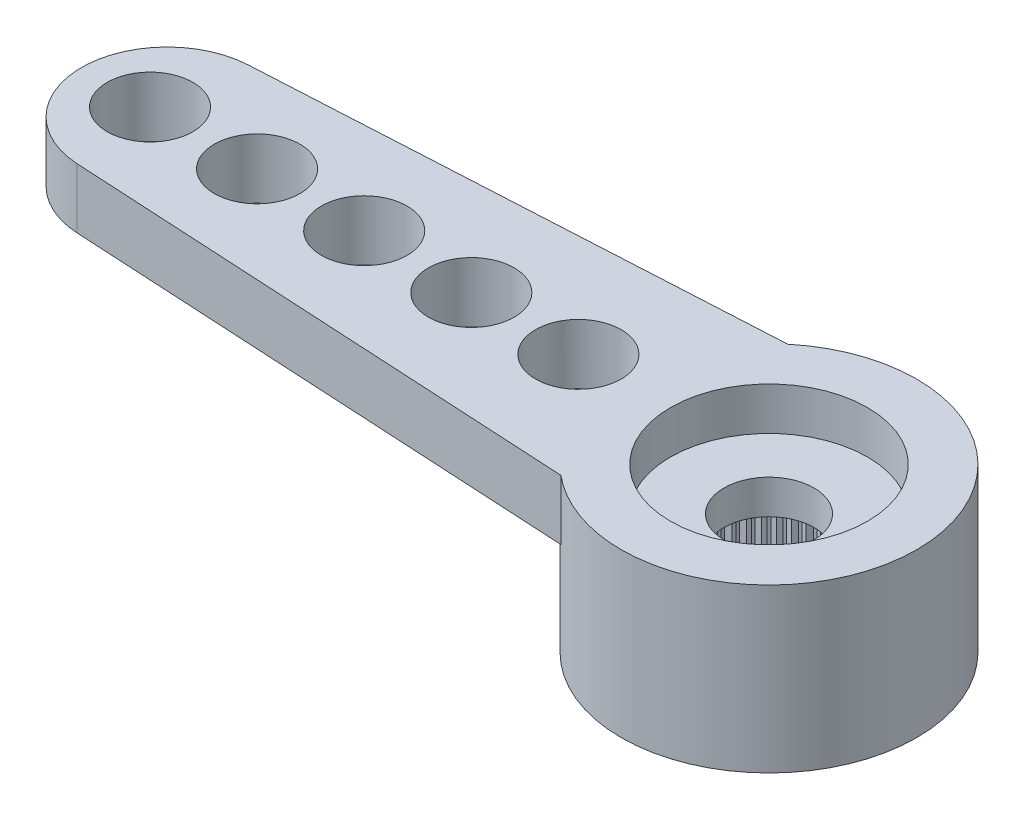
from build123d import *

# Parameters (mm, degrees)
RESSALTO_EXTRUS_O1_DEPTH = 1.4
ESBO_O2_R                = 3.45
RESSALTO_EXTRUS_O2_DEPTH = 2.4
FURO4_D                  = 2
PADR_O_LINEAR1_COUNT     = 5
PADR_O_LINEAR1_PITCH     = 2.5
FURO1_D                  = 4.95
FURO1_DEPTH              = 2
FURO2_D                  = 4.6
FURO2_DEPTH              = 1
FURO3_D                  = 2.1
RESSALTO_EXTRUS_O3_DEPTH = 2
PADR_OCIRCULAR1_COUNT    = 60


with BuildPart() as part:
    # Esboço1 → Ressalto-extrusão1 (new body)
    with BuildSketch(Plane(origin=(0, 0, 0), x_dir=(1, 0, 0), z_dir=(0, 1, 0))):
        with BuildLine():
            Line((-14.159121967, 1.99702088), (-2.209072203, 2.65))
            ThreePointArc((-2.209072203, 2.65), (3.45, 0), (-2.209072203, -2.65))
            Line((-2.209072203, -2.65), (-14.159121967, -1.99702088))
            ThreePointArc((-14.159121967, -1.99702088), (-16.05, 0), (-14.159121967, 1.99702088))
        make_face()
    extrude(amount=-RESSALTO_EXTRUS_O1_DEPTH)

    # Esboço2 → Ressalto-extrusão2 (add)
    with BuildSketch(Plane.XZ.offset(1.4)):
        Circle(ESBO_O2_R)
    extrude(amount=RESSALTO_EXTRUS_O2_DEPTH)

    # Furo4 (through all)
    with Locations(Plane(origin=(0, 0, 0), x_dir=(1, 0, 0), z_dir=(0, 1, 0))):
        with Locations((-14.45, 0)):
            furo4 = Hole(FURO4_D / 2)

    # Padrão linear1: Furo4 ×5
    with Locations(*[(i * PADR_O_LINEAR1_PITCH, 0, 0) for i in range(1, PADR_O_LINEAR1_COUNT)]):
        add(furo4, mode=Mode.SUBTRACT)

    # Furo1
    with Locations(Plane(origin=(0, -3.8, 0), x_dir=(-1, 0, 0), z_dir=(0, -1, 0))):
        with Locations((0, 0)):
            Hole(FURO1_D / 2, depth=FURO1_DEPTH)

    # Furo2
    with Locations(Plane(origin=(0, 0, 0), x_dir=(1, 0, 0), z_dir=(0, 1, 0))):
        with Locations((0, 0)):
            Hole(FURO2_D / 2, depth=FURO2_DEPTH)

    # Furo3 (through all)
    with Locations(Plane(origin=(0, 0, 0), x_dir=(1, 0, 0), z_dir=(0, 1, 0))):
        with Locations((0, 0)):
            Hole(FURO3_D / 2)

    # Esboço11 → Ressalto-extrusão3 (add)
    with BuildSketch(Plane.XZ.offset(3.8)):
        with BuildLine():
            Line((-0.098056786, 2.473056786), (0, 2.375))
            Line((0, 2.375), (0.098056786, 2.473056786))
            ThreePointArc((0.098056786, 2.473056786), (0, 2.475), (-0.098056786, 2.473056786))
        make_face()
    ressalto_extrus_o3 = extrude(amount=-RESSALTO_EXTRUS_O3_DEPTH)

    # PadrãoCircular1: Ressalto-extrusão3 ×60 about axis
    padr_ocircular1_axis = Axis((0, 0, 0), (0, 1, 0))
    for i in range(1, PADR_OCIRCULAR1_COUNT):
        add(ressalto_extrus_o3.rotate(padr_ocircular1_axis, i * 360 / PADR_OCIRCULAR1_COUNT))


solid = part.part
